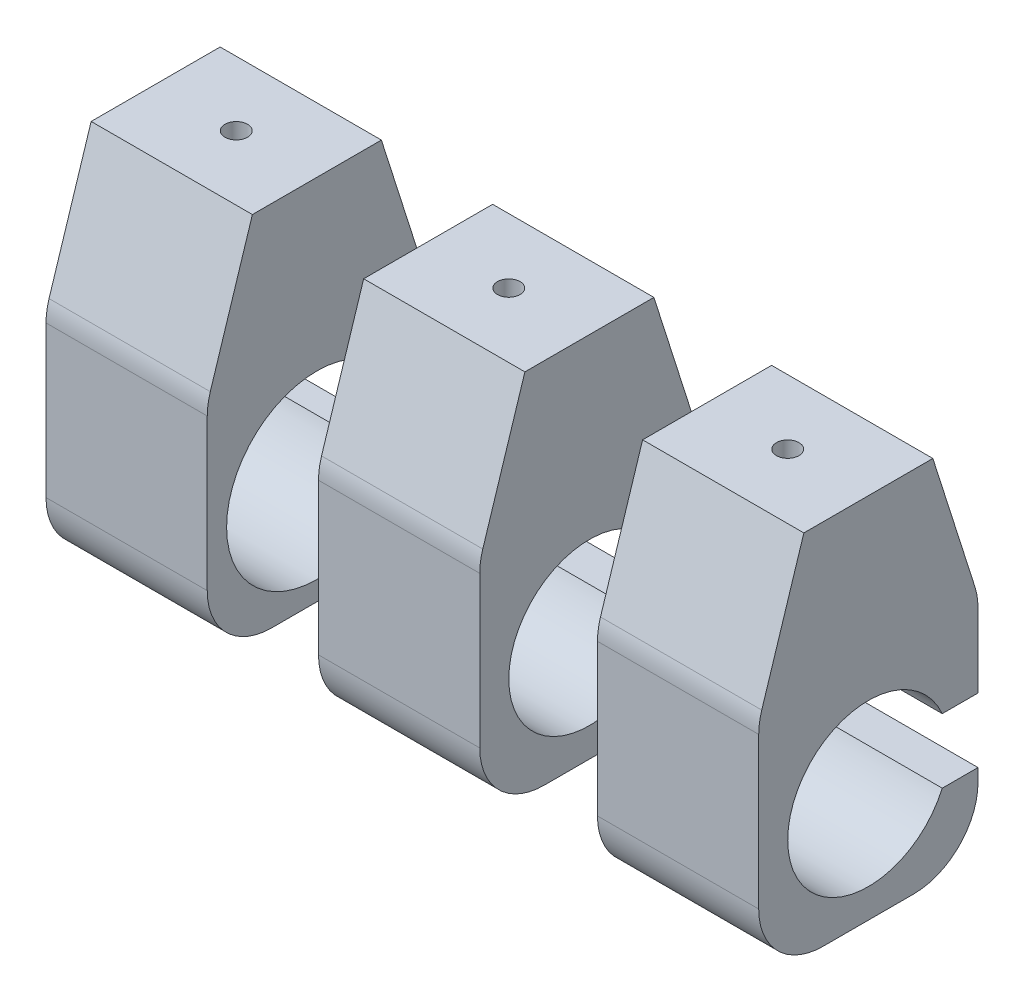
from build123d import *

# Parameters (mm, degrees)
ZOOM_LENSE_MOUNT_DEPTH = 25
SPEC_START             = 42.25
SPEC_MOUNT1_DEPTH      = 25
SPEC_START_2           = 85.5
SPEC_MOUNT_2_DEPTH     = 25
FILLET1_R              = 10
FILLET2_R              = 10
FILLET3_R              = 10
SKETCH2_R              = 1.75
CUT_EXTRUDE1_DEPTH     = 30
SKETCH3_R              = 1.75
CUT_EXTRUDE2_DEPTH     = 30
SKETCH4_R              = 1.75
CUT_EXTRUDE3_DEPTH     = 30


with BuildPart() as part:
    # Sketch1 → zoom lense mount (new body)
    with BuildSketch(Plane(origin=(0, 0, 0), x_dir=(0, 0, -1), z_dir=(1, 0, 0))):
        with BuildLine():
            Line((10, 40), (-10, 40))
            Line((-10, 40), (-17, 18))
            Line((-17, 18), (-17, -17))
            Line((-17, -17), (17, -17))
            Line((17, -17), (17, -5))
            Line((17, -5), (13.076696831, -5))
            ThreePointArc((13.076696831, -5), (-14, 0), (13.076696831, 5))
            Line((13.076696831, 5), (17, 5))
            Line((17, 5), (17, 18))
            Line((17, 18), (10, 40))
        make_face()
    extrude(amount=ZOOM_LENSE_MOUNT_DEPTH)

    # Fillet1
    fillet1_edges = [part.edges().sort_by_distance(p)[0] for p in [
        (12.5, -17, -17),
        (12.5, 18, -17),
        (12.5, -17, 17),
        (12.5, 18, 17),
    ]]
    fillet(fillet1_edges, radius=FILLET1_R)

    # Sketch4 → Cut-Extrude3 (cut)
    with BuildSketch(Plane(origin=(0, 40, 0), x_dir=(1, 0, 0), z_dir=(0, 1, 0))):
        with Locations((12.5, 0)):
            Circle(SKETCH4_R)
    extrude(amount=-CUT_EXTRUDE3_DEPTH, mode=Mode.SUBTRACT)


with BuildPart() as body_2:
    # Sketch1_4 → spec mount1 (new body)
    with BuildSketch(Plane(origin=(0, 0, 0), x_dir=(0, 0, -1), z_dir=(1, 0, 0)).offset(SPEC_START)):
        with BuildLine():
            Line((10, 40), (-10, 40))
            Line((-10, 40), (-17, 18))
            Line((-17, 18), (-17, -17))
            Line((-17, -17), (17, -17))
            Line((17, -17), (17, -5))
            Line((17, -5), (11.456439237, -5))
            ThreePointArc((11.456439237, -5), (-12.5, 0), (11.456439237, 5))
            Line((11.456439237, 5), (17, 5))
            Line((17, 5), (17, 18))
            Line((17, 18), (10, 40))
        make_face()
    extrude(amount=SPEC_MOUNT1_DEPTH)

    # Fillet2
    fillet2_edges = [body_2.edges().sort_by_distance(p)[0] for p in [
        (54.75, -17, -17),
        (54.75, 18, -17),
        (54.75, -17, 17),
        (54.75, 18, 17),
    ]]
    fillet(fillet2_edges, radius=FILLET2_R)

    # Sketch3 → Cut-Extrude2 (cut)
    with BuildSketch(Plane(origin=(0, 40, 0), x_dir=(1, 0, 0), z_dir=(0, 1, 0))):
        with Locations((54.75, 0)):
            Circle(SKETCH3_R)
    extrude(amount=-CUT_EXTRUDE2_DEPTH, mode=Mode.SUBTRACT)


with BuildPart() as body_3:
    # Sketch1_5 → spec mount 2 (new body)
    with BuildSketch(Plane(origin=(0, 0, 0), x_dir=(0, 0, -1), z_dir=(1, 0, 0)).offset(SPEC_START_2)):
        with BuildLine():
            Line((10, 40), (-10, 40))
            Line((-10, 40), (-17, 18))
            Line((-17, 18), (-17, -17))
            Line((-17, -17), (17, -17))
            Line((17, -17), (17, -5))
            Line((17, -5), (11.456439237, -5))
            ThreePointArc((11.456439237, -5), (-12.5, 0), (11.456439237, 5))
            Line((11.456439237, 5), (17, 5))
            Line((17, 5), (17, 18))
            Line((17, 18), (10, 40))
        make_face()
    extrude(amount=SPEC_MOUNT_2_DEPTH)

    # Fillet3
    fillet3_edges = [body_3.edges().sort_by_distance(p)[0] for p in [
        (98, -17, -17),
        (98, 18, -17),
        (98, -17, 17),
        (98, 18, 17),
    ]]
    fillet(fillet3_edges, radius=FILLET3_R)

    # Sketch2 → Cut-Extrude1 (cut)
    with BuildSketch(Plane(origin=(0, 40, 0), x_dir=(1, 0, 0), z_dir=(0, 1, 0))):
        with Locations((98, 0)):
            Circle(SKETCH2_R)
    extrude(amount=-CUT_EXTRUDE1_DEPTH, mode=Mode.SUBTRACT)


solid = Compound([part.part, body_2.part, body_3.part])
